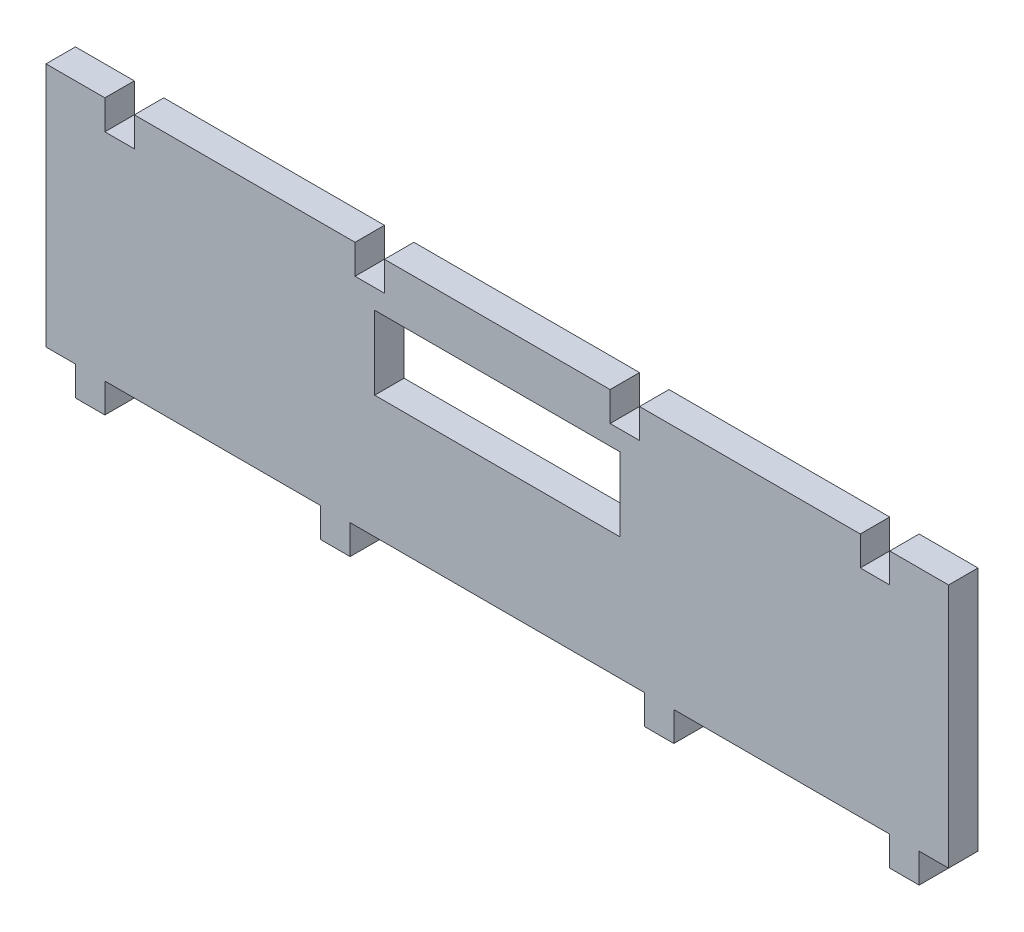
from build123d import *

# Parameters (mm, degrees)
SKETCH1_W           = 184
SKETCH1_H           = 50
BOSS_EXTRUDE2_DEPTH = 6
SKETCH7_W           = 6
SKETCH7_H           = 6
CUT_EXTRUDE3_DEPTH  = 6
SKETCH8_W           = 50
SKETCH8_H           = 15
CUT_EXTRUDE4_DEPTH  = 6
SKETCH9_W           = 6
SKETCH9_H           = 6
BOSS_EXTRUDE3_DEPTH = 6


with BuildPart() as part:
    # Sketch1 → Boss-Extrude2 (new body)
    with BuildSketch(Plane.XY):
        with Locations((0, 25)):
            Rectangle(SKETCH1_W, SKETCH1_H)
    extrude(amount=BOSS_EXTRUDE2_DEPTH)

    # Sketch7 → Cut-Extrude3 (cut)
    with BuildSketch(Plane.XY):
        with Locations((77, 47)):
            Rectangle(SKETCH7_W, SKETCH7_H)
        with Locations((26, 47)):
            Rectangle(SKETCH7_W, SKETCH7_H)
        with Locations((-77, 47)):
            Rectangle(SKETCH7_W, SKETCH7_H)
        with Locations((-26, 47)):
            Rectangle(SKETCH7_W, SKETCH7_H)
    extrude(amount=CUT_EXTRUDE3_DEPTH, mode=Mode.SUBTRACT)

    # Sketch8 → Cut-Extrude4 (cut)
    with BuildSketch(Plane(origin=(0, 0, 0), x_dir=(-1, 0, 0), z_dir=(0, 0, -1))):
        with Locations((0, 32.5)):
            Rectangle(SKETCH8_W, SKETCH8_H)
    extrude(amount=-CUT_EXTRUDE4_DEPTH, mode=Mode.SUBTRACT)

    # Sketch9 → Boss-Extrude3 (add)
    with BuildSketch(Plane.XZ):
        with Locations((-83, 3)):
            Rectangle(SKETCH9_W, SKETCH9_H)
        with Locations((-33, 3)):
            Rectangle(SKETCH9_W, SKETCH9_H)
        with Locations((33, 3)):
            Rectangle(SKETCH9_W, SKETCH9_H)
        with Locations((83, 3)):
            Rectangle(SKETCH9_W, SKETCH9_H)
    extrude(amount=BOSS_EXTRUDE3_DEPTH)


solid = part.part
